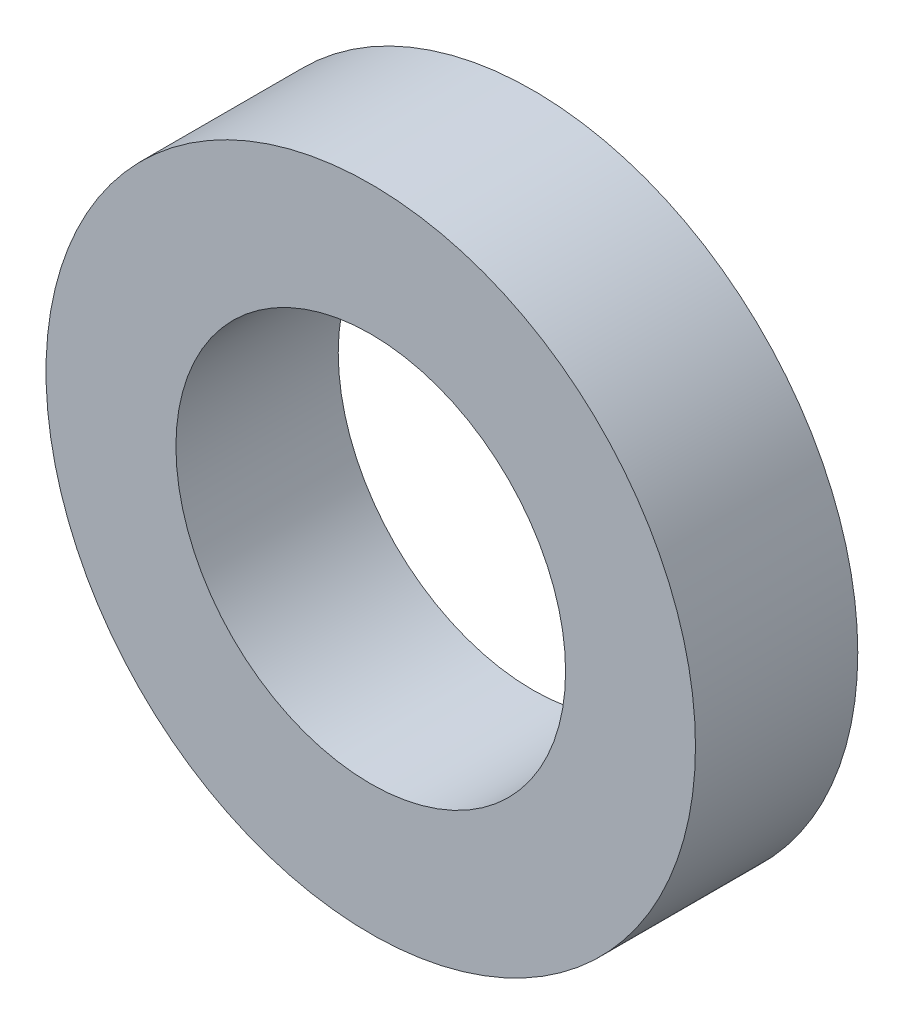
from build123d import *

# Parameters (mm, degrees)
SKETCH1_R           = 7.9375
SKETCH1_R_2         = 4.7625
BOSS_EXTRUDE1_DEPTH = 3.96748


with BuildPart() as part:
    # Sketch1 → Boss-Extrude1 (new body)
    with BuildSketch(Plane.XY):
        Circle(SKETCH1_R)
        Circle(SKETCH1_R_2, mode=Mode.SUBTRACT)
    extrude(amount=BOSS_EXTRUDE1_DEPTH)


solid = part.part
